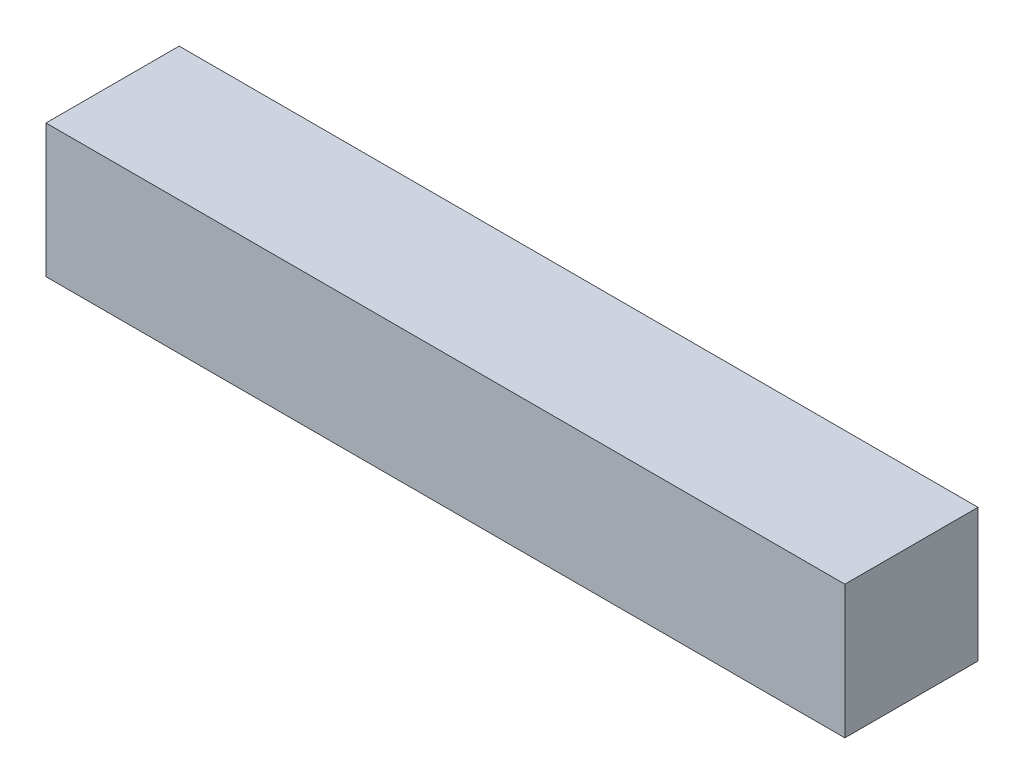
from build123d import *

# Parameters (mm, degrees)
SKETCH1_W           = 25.4
SKETCH1_H           = 25.4
BOSS_EXTRUDE1_DEPTH = 152.4


with BuildPart() as part:
    # Sketch1 → Boss-Extrude1 (new body)
    with BuildSketch(Plane(origin=(0, 0, 0), x_dir=(0, 0, -1), z_dir=(1, 0, 0))):
        with Locations((-12.7, 12.7)):
            Rectangle(SKETCH1_W, SKETCH1_H)
    extrude(amount=BOSS_EXTRUDE1_DEPTH)


solid = part.part
